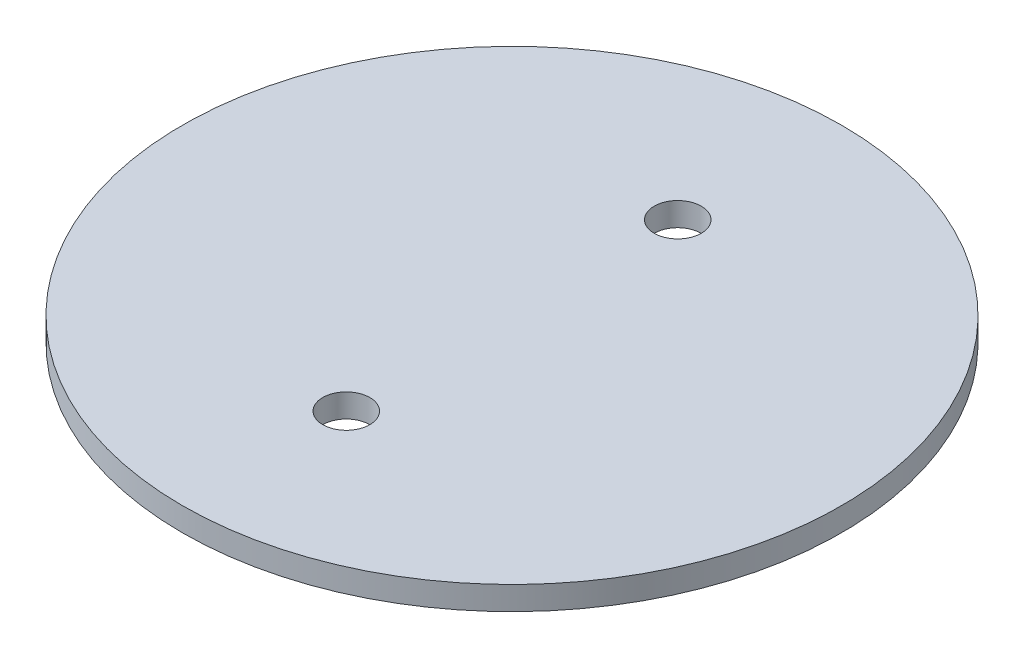
from build123d import *

# Parameters (mm, degrees)
SKETCH1_R           = 44.45
SKETCH1_R_2         = 3.175
BOSS_EXTRUDE1_DEPTH = 3.175


with BuildPart() as part:
    # Sketch1 → Boss-Extrude1 (new body)
    with BuildSketch(Plane(origin=(0, 0, 0), x_dir=(1, 0, 0), z_dir=(0, 1, 0))):
        Circle(SKETCH1_R)
        with Locations((0, -22.352)):
            Circle(SKETCH1_R_2, mode=Mode.SUBTRACT)
        with Locations((0, 22.352)):
            Circle(SKETCH1_R_2, mode=Mode.SUBTRACT)
    extrude(amount=BOSS_EXTRUDE1_DEPTH)


solid = part.part
